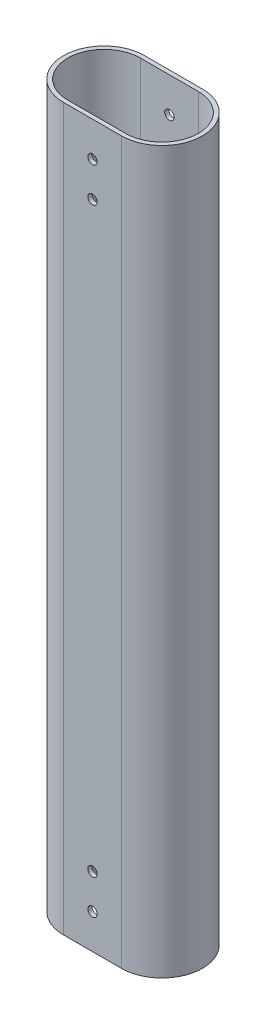
from build123d import *

# Parameters (mm, degrees)
EXTRUDE_1_DEPTH       = 311.4
HOLE_WIZARD_10_32_1_D = 4.0386


with BuildPart() as part:
    # 草圖1 → 填料-伸長1 (new body)
    with BuildSketch(Plane(origin=(0, 0, 0), x_dir=(1, 0, 0), z_dir=(0, 1, 0))):
        with BuildLine():
            Line((-12.5, 17.5), (12.5, 17.5))
            ThreePointArc((12.5, 17.5), (30, 0), (12.5, -17.5))
            Line((12.5, -17.5), (-12.5, -17.5))
            ThreePointArc((-12.5, -17.5), (-30, 0), (-12.5, 17.5))
        make_face()
        with BuildLine():
            Line((-12.5, 15.7), (12.5, 15.7))
            ThreePointArc((12.5, 15.7), (28.2, 0), (12.5, -15.7))
            Line((12.5, -15.7), (-12.5, -15.7))
            ThreePointArc((-12.5, -15.7), (-28.2, 0), (-12.5, 15.7))
        make_face(mode=Mode.SUBTRACT)
    extrude(amount=EXTRUDE_1_DEPTH)

    # #10-32 螺紋孔1 (through all)
    with Locations(Plane.XY.offset(17.5)):
        with Locations((0, 15), (0, 30), (0, 296.4), (0, 281.4)):
            Hole(HOLE_WIZARD_10_32_1_D / 2)


solid = part.part
